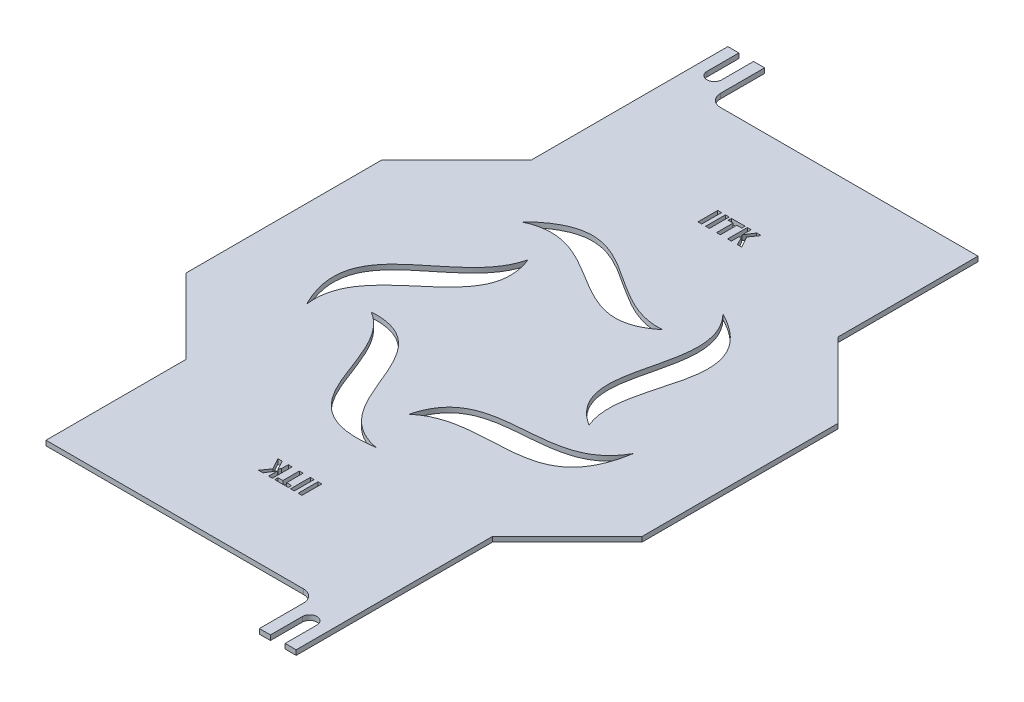
from build123d import *

# Parameters (mm, degrees)
BOSS_EXTRUDE1_DEPTH = 2
CUT_EXTRUDE1_DEPTH  = 10
CUT_EXTRUDE2_DEPTH  = 10
SKETCH4_W           = 25
SKETCH4_H           = 23
CUT_EXTRUDE3_DEPTH  = 10
SKETCH5_W           = 22.902006328
SKETCH5_H           = 46
SKETCH5_W_2         = 10
SKETCH5_H_2         = 23
CUT_EXTRUDE4_DEPTH  = 10
SKETCH6_W           = 9
SKETCH6_H           = 23
BOSS_EXTRUDE2_DEPTH = 2
CUT_EXTRUDE5_DEPTH  = 10
SKETCH8_W           = 86.69200045
SKETCH8_H           = 23
CUT_EXTRUDE6_DEPTH  = 10
FILLET1_R           = 5
SKETCH9_W           = 15
SKETCH9_H           = 23
BOSS_EXTRUDE3_DEPTH = 2
SKETCH10_W          = 8.130606678
SKETCH10_H          = 25.213230542
CUT_EXTRUDE7_DEPTH  = 10
CUT_EXTRUDE8_DEPTH  = 10
FILLET2_R           = 5
SKETCH12_W          = 1.546136562
SKETCH12_H          = 8.071555555
SKETCH12_W_2        = 1.546136563
CUT_EXTRUDE10_DEPTH = 10


with BuildPart() as part:
    # Sketch1 → Boss-Extrude1 (new body)
    with BuildSketch(Plane(origin=(0, 0, 0), x_dir=(1, 0, 0), z_dir=(0, 1, 0))):
        Polygon((62.5, 150.5), (-62.5, 150.5), (-62.5, 70.5), (-93, 40), (-93, -40), (-62.5, -70.5), (-62.5, -150.5), (62.5, -150.5), (62.5, -70.5), (93, -40), (93, 40), (62.5, 70.5), align=None)
    extrude(amount=BOSS_EXTRUDE1_DEPTH)

    # Sketch2 → Cut-Extrude1 (cut)
    with BuildSketch(Plane(origin=(0, 2, 0), x_dir=(1, 0, 0), z_dir=(0, 1, 0))):
        with BuildLine():
            Line((3, 150.5), (-3, 150.5))
            Line((-3, 150.5), (-3, 137.5))
            ThreePointArc((-3, 137.5), (0, 134.5), (3, 137.5))
            Line((3, 137.5), (3, 150.5))
        make_face()
        with BuildLine():
            Line((-3, -150.5), (3, -150.5))
            Line((3, -150.5), (3, -137.5))
            ThreePointArc((3, -137.5), (0, -134.5), (-3, -137.5))
            Line((-3, -137.5), (-3, -150.5))
        make_face()
    extrude(amount=-CUT_EXTRUDE1_DEPTH, mode=Mode.SUBTRACT)

    # Sketch3 → Cut-Extrude2 (cut)
    with BuildSketch(Plane(origin=(0, 2, 0), x_dir=(1, 0, 0), z_dir=(0, 1, 0))):
        with BuildLine():
            add(Edge.make_bspline(
                [(61.935330863, -12.480671207), (48.18812645, -37.764846848), (10.15230333, -13.930676571), (2.340125851, -44.306382784)],
                knots=[0, 0, 0, 0, 1, 1, 1, 1], degree=3))
            add(Edge.make_bspline(
                [(61.935330863, -12.480671207), (55.762093107, -50.458165256), (21.338028868, -28.075008023), (2.340125851, -44.306382784)],
                knots=[0, 0, 0, 0, 1, 1, 1, 1], degree=3))
        make_face()
        with BuildLine():
            add(Edge.make_bspline(
                [(7.26924611, -62.76073951), (-21.025553682, -57.499611134), (-10.111626468, -13.960230041), (-41.414735403, -15.917017179)],
                knots=[0, 0, 0, 0, 1, 1, 1, 1], degree=3))
            add(Edge.make_bspline(
                [(7.26924611, -62.76073951), (-30.757132455, -68.62533258), (-20.107105779, -28.969325996), (-41.414735403, -15.917017179)],
                knots=[0, 0, 0, 0, 1, 1, 1, 1], degree=3))
        make_face()
        with BuildLine():
            add(Edge.make_bspline(
                [(-57.442689694, -26.30759897), (-61.182633257, 2.228132827), (-16.401632169, 5.302779915), (-27.935839965, 34.469125167)],
                knots=[0, 0, 0, 0, 1, 1, 1, 1], degree=3))
            add(Edge.make_bspline(
                [(-57.442689694, -26.30759897), (-74.77104636, 8.045377232), (-33.764903654, 10.170979926), (-27.935839965, 34.469125167)],
                knots=[0, 0, 0, 0, 1, 1, 1, 1], degree=3))
        make_face()
        with BuildLine():
            add(Edge.make_bspline(
                [(-42.770780746, 46.501749184), (-16.787393193, 58.876672953), (-0.025139683, 17.237528263), (24.1494368, 37.220108095)],
                knots=[0, 0, 0, 0, 1, 1, 1, 1], degree=3))
            add(Edge.make_bspline(
                [(-42.770780746, 46.501749184), (-15.45391557, 73.597649162), (-0.760752306, 35.255337289), (24.1494368, 37.220108095)],
                knots=[0, 0, 0, 0, 1, 1, 1, 1], degree=3))
        make_face()
        with BuildLine():
            add(Edge.make_bspline(
                [(31.008893468, 55.047260502), (50.807453682, 34.159652202), (16.38609499, 5.350598434), (42.861012717, -11.4658333)],
                knots=[0, 0, 0, 0, 1, 1, 1, 1], degree=3))
            add(Edge.make_bspline(
                [(31.008893468, 55.047260502), (65.220001279, 37.440471442), (33.294732872, 11.618016803), (42.861012717, -11.4658333)],
                knots=[0, 0, 0, 0, 1, 1, 1, 1], degree=3))
        make_face()
    extrude(amount=-CUT_EXTRUDE2_DEPTH, mode=Mode.SUBTRACT)

    # Sketch4 → Cut-Extrude3 (cut)
    with BuildSketch(Plane(origin=(0, 2, 0), x_dir=(1, 0, 0), z_dir=(0, 1, 0))):
        Polygon((31.5, 173.5), (31.5, 150.5), (44, 150.5), (56.5, 150.5), (56.5, 173.5), align=None)
        Polygon((44, 150.5), (31.5, 150.5), (31.5, 127.5), (56.5, 127.5), (56.5, 150.5), align=None)
        with Locations((-44, 139)):
            Rectangle(SKETCH4_W, SKETCH4_H)
        with Locations((-44, 162)):
            Rectangle(SKETCH4_W, SKETCH4_H)
        with Locations((-44, -162)):
            Rectangle(SKETCH4_W, SKETCH4_H)
        with Locations((-44, -139)):
            Rectangle(SKETCH4_W, SKETCH4_H)
        Polygon((31.5, -127.5), (31.5, -150.5), (44, -150.5), (56.5, -150.5), (56.5, -127.5), align=None)
        Polygon((31.5, -150.5), (31.5, -173.5), (56.5, -173.5), (56.5, -150.5), (44, -150.5), align=None)
    extrude(amount=-CUT_EXTRUDE3_DEPTH, mode=Mode.SUBTRACT)

    # Sketch5 → Cut-Extrude4 (cut)
    with BuildSketch(Plane(origin=(0, 2, 0), x_dir=(1, 0, 0), z_dir=(0, 1, 0))):
        with Locations((56.5, 150.5)):
            Rectangle(SKETCH5_W, SKETCH5_H)
        with Locations((-26.5, 139)):
            Rectangle(SKETCH5_W_2, SKETCH5_H_2)
    extrude(amount=-CUT_EXTRUDE4_DEPTH, mode=Mode.SUBTRACT)

    # Sketch6 → Boss-Extrude2 (add)
    with BuildSketch(Plane(origin=(0, 2, 0), x_dir=(1, 0, 0), z_dir=(0, 1, 0))):
        with Locations((-52, 139)):
            Rectangle(SKETCH6_W, SKETCH6_H)
    extrude(amount=-BOSS_EXTRUDE2_DEPTH)

    # Sketch7 → Cut-Extrude5 (cut)
    with BuildSketch(Plane(origin=(0, 2, 0), x_dir=(1, 0, 0), z_dir=(0, 1, 0))):
        with BuildLine():
            Line((-52, 150.5), (-52, 137.5))
            ThreePointArc((-52, 137.5), (-55, 134.5), (-58, 137.5))
            Line((-58, 137.5), (-58, 150.5))
            Line((-58, 150.5), (-52, 150.5))
        make_face()
    extrude(amount=-CUT_EXTRUDE5_DEPTH, mode=Mode.SUBTRACT)

    # Sketch8 → Cut-Extrude6 (cut)
    with BuildSketch(Plane(origin=(0, 2, 0), x_dir=(1, 0, 0), z_dir=(0, 1, 0))):
        with Locations((-4.153999775, 139)):
            Rectangle(SKETCH8_W, SKETCH8_H)
    cut_extrude6 = extrude(amount=-CUT_EXTRUDE6_DEPTH, mode=Mode.SUBTRACT)

    # Fillet1
    fillet1_edges = [part.edges().sort_by_distance(p)[0] for p in [
        (-47.5, 1, -127.5),
    ]]
    fillet(fillet1_edges, radius=FILLET1_R)

    # Mirror1: Cut-Extrude6 across plane
    add(cut_extrude6.mirror(Plane.XY), mode=Mode.SUBTRACT)

    # Sketch9 → Boss-Extrude3 (add)
    with BuildSketch(Plane(origin=(0, 2, 0), x_dir=(1, 0, 0), z_dir=(0, 1, 0))):
        with Locations((55, -139)):
            Rectangle(SKETCH9_W, SKETCH9_H)
    extrude(amount=-BOSS_EXTRUDE3_DEPTH)

    # Sketch10 → Cut-Extrude7 (cut)
    with BuildSketch(Plane(origin=(0, 2, 0), x_dir=(1, 0, 0), z_dir=(0, 1, 0))):
        with Locations((-60.565303339, -140.106615271)):
            Rectangle(SKETCH10_W, SKETCH10_H)
    extrude(amount=-CUT_EXTRUDE7_DEPTH, mode=Mode.SUBTRACT)

    # Sketch11 → Cut-Extrude8 (cut)
    with BuildSketch(Plane(origin=(0, 2, 0), x_dir=(1, 0, 0), z_dir=(0, 1, 0))):
        with BuildLine():
            Line((58, -150.5), (58, -137.5))
            ThreePointArc((58, -137.5), (55, -134.5), (52, -137.5))
            Line((52, -137.5), (52, -150.5))
            Line((52, -150.5), (58, -150.5))
        make_face()
    extrude(amount=-CUT_EXTRUDE8_DEPTH, mode=Mode.SUBTRACT)

    # Fillet2
    fillet2_edges = [part.edges().sort_by_distance(p)[0] for p in [
        (47.5, 1, 127.5),
    ]]
    fillet(fillet2_edges, radius=FILLET2_R)

    # Sketch12 → Cut-Extrude10 (cut)
    with BuildSketch(Plane(origin=(0, 2, 0), x_dir=(1, 0, 0), z_dir=(0, 1, 0))):
        with BuildLine():
            Line((11.057236963, 90.577641215), (9.205936139, 90.577641215))
            Line((9.205936139, 90.577641215), (7.470341617, 87.848785269))
            add(Edge.make_bspline(
                [(7.470341617, 87.848785269), (7.384227031, 87.695784737), (7.211017763, 87.388042327), (7.039863479, 87.079152278), (6.953802103, 86.923833333)],
                knots=[0, 0, 0, 0, 0.000526709, 0.001059412, 0.001059412, 0.001059412, 0.001059412], degree=3))
            Line((6.953802103, 86.923833333), (6.923366374, 86.925096535))
            Line((6.923366374, 86.925096535), (6.923366374, 90.577641215))
            Line((6.923366374, 90.577641215), (5.377229811, 90.577641215))
            Line((5.377229811, 90.577641215), (5.377229811, 82.50608566))
            Line((5.377229811, 82.50608566), (6.923366374, 82.50608566))
            Line((6.923366374, 82.50608566), (6.923366374, 85.266655399))
            Line((6.923366374, 85.266655399), (7.52293539, 86.074883041))
            Line((7.52293539, 86.074883041), (9.395273724, 82.50608566))
            Line((9.395273724, 82.50608566), (11.172943265, 82.50608566))
            Line((11.172943265, 82.50608566), (8.616885877, 87.12452933))
            Line((8.616885877, 87.12452933), (11.057236963, 90.577641215))
        make_face()
        Polygon((-1.090954257, 90.575166826), (-1.090954257, 89.228766227), (0.897090378, 89.228766227), (0.897090378, 82.50608566), (2.44322694, 82.50608566), (2.44322694, 89.228766227), (4.441790329, 89.228766227), (4.441790329, 90.575166826), align=None)
        with Locations((-2.809980775, 86.541863438)):
            Rectangle(SKETCH12_W, SKETCH12_H)
        with Locations((-5.926599511, 86.541863438)):
            Rectangle(SKETCH12_W, SKETCH12_H)
        with BuildLine():
            Line((-8.592214649, -94.801855155), (-6.740913825, -94.801855155))
            Line((-6.740913825, -94.801855155), (-5.005319303, -92.072999209))
            add(Edge.make_bspline(
                [(-5.005319303, -92.072999209), (-4.919754963, -91.920481841), (-4.747310742, -91.613102168), (-4.576405897, -91.304863925), (-4.490301576, -91.14956906)],
                knots=[0, 0, 0, 0, 0.000524637, 0.001057341, 0.001057341, 0.001057341, 0.001057341], degree=3))
            Line((-4.490301576, -91.14956906), (-4.458344059, -91.149310475))
            Line((-4.458344059, -91.149310475), (-4.458344059, -94.801855155))
            Line((-4.458344059, -94.801855155), (-2.912207497, -94.801855155))
            Line((-2.912207497, -94.801855155), (-2.912207497, -86.7302996))
            Line((-2.912207497, -86.7302996), (-4.458344059, -86.7302996))
            Line((-4.458344059, -86.7302996), (-4.458344059, -89.490869339))
            Line((-4.458344059, -89.490869339), (-5.057913076, -90.299096981))
            Line((-5.057913076, -90.299096981), (-6.930251409, -86.7302996))
            Line((-6.930251409, -86.7302996), (-8.70792095, -86.7302996))
            Line((-8.70792095, -86.7302996), (-6.151863563, -91.34874327))
            Line((-6.151863563, -91.34874327), (-8.592214649, -94.801855155))
        make_face()
        Polygon((3.555976571, -94.799380766), (3.555976571, -93.452980167), (1.567931937, -93.452980167), (1.567931937, -86.7302996), (0.021795374, -86.7302996), (0.021795374, -93.452980167), (-1.976768015, -93.452980167), (-1.976768015, -94.799380766), align=None)
        with Locations((5.275003089, -90.766077378)):
            Rectangle(SKETCH12_W, SKETCH12_H)
        with Locations((8.391621825, -90.766077378)):
            Rectangle(SKETCH12_W_2, SKETCH12_H)
    extrude(amount=-CUT_EXTRUDE10_DEPTH, mode=Mode.SUBTRACT)


solid = part.part
